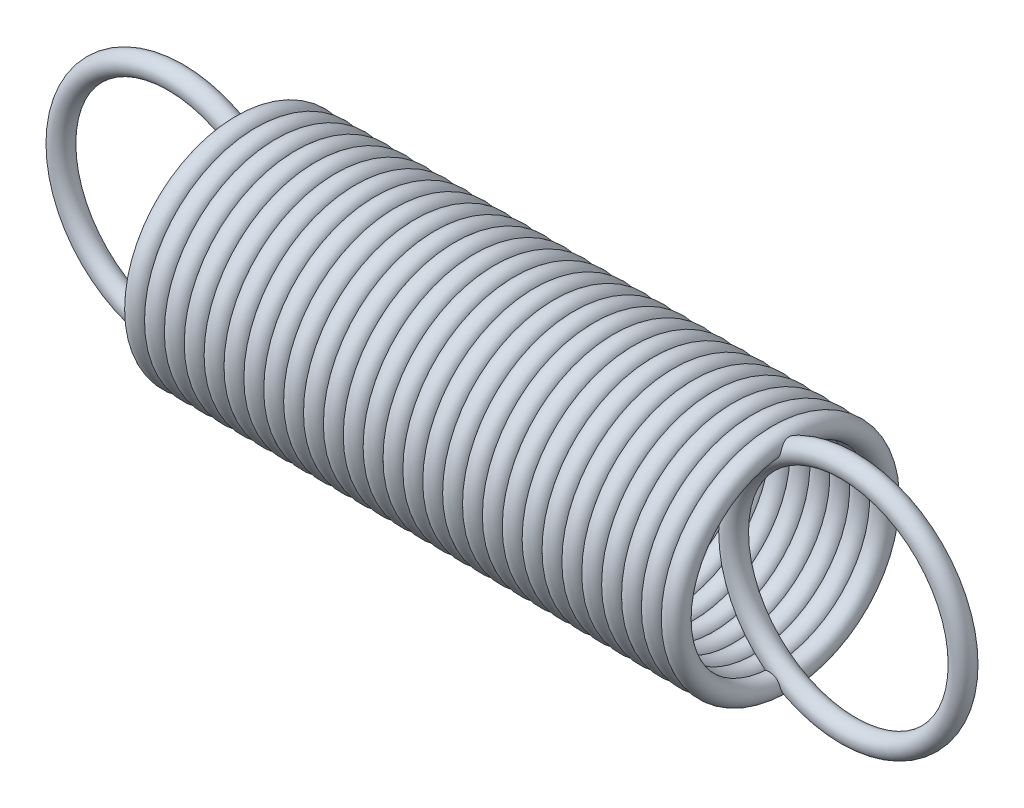
from build123d import *

# Parameters (mm, degrees)
SKETCH4_R       = 0.2921
LPATTERN3_COUNT = 28
LPATTERN3_PITCH = 0.55
SKETCH3_R       = 0.2921
SKETCH7_R       = 0.2921


with BuildPart() as part:
    # Sketch4 → Revolve2 (revolve)
    with BuildSketch(Plane(origin=(0, 0, 0), x_dir=(1, 0, 0), z_dir=(0, 1, 0))):
        with Locations((0, 2.8829)):
            Circle(SKETCH4_R)
    revolve(axis=Axis((-3.147709024, 0, 0), (1, 0, 0)))


with BuildPart() as lpattern3_1:
    # LPattern3: pattern copy
    add(part.part.moved(Location(Vector(1, 0, 0) * (1 * LPATTERN3_PITCH))))


with BuildPart() as lpattern3_2:
    # LPattern3: pattern copy
    add(part.part.moved(Location(Vector(1, 0, 0) * (2 * LPATTERN3_PITCH))))


with BuildPart() as lpattern3_3:
    # LPattern3: pattern copy
    add(part.part.moved(Location(Vector(1, 0, 0) * (3 * LPATTERN3_PITCH))))


with BuildPart() as lpattern3_4:
    # LPattern3: pattern copy
    add(part.part.moved(Location(Vector(1, 0, 0) * (4 * LPATTERN3_PITCH))))


with BuildPart() as lpattern3_5:
    # LPattern3: pattern copy
    add(part.part.moved(Location(Vector(1, 0, 0) * (5 * LPATTERN3_PITCH))))


with BuildPart() as lpattern3_6:
    # LPattern3: pattern copy
    add(part.part.moved(Location(Vector(1, 0, 0) * (6 * LPATTERN3_PITCH))))


with BuildPart() as lpattern3_7:
    # LPattern3: pattern copy
    add(part.part.moved(Location(Vector(1, 0, 0) * (7 * LPATTERN3_PITCH))))


with BuildPart() as lpattern3_8:
    # LPattern3: pattern copy
    add(part.part.moved(Location(Vector(1, 0, 0) * (8 * LPATTERN3_PITCH))))


with BuildPart() as lpattern3_9:
    # LPattern3: pattern copy
    add(part.part.moved(Location(Vector(1, 0, 0) * (9 * LPATTERN3_PITCH))))


with BuildPart() as lpattern3_10:
    # LPattern3: pattern copy
    add(part.part.moved(Location(Vector(1, 0, 0) * (10 * LPATTERN3_PITCH))))


with BuildPart() as lpattern3_11:
    # LPattern3: pattern copy
    add(part.part.moved(Location(Vector(1, 0, 0) * (11 * LPATTERN3_PITCH))))


with BuildPart() as lpattern3_12:
    # LPattern3: pattern copy
    add(part.part.moved(Location(Vector(1, 0, 0) * (12 * LPATTERN3_PITCH))))


with BuildPart() as lpattern3_13:
    # LPattern3: pattern copy
    add(part.part.moved(Location(Vector(1, 0, 0) * (13 * LPATTERN3_PITCH))))


with BuildPart() as lpattern3_14:
    # LPattern3: pattern copy
    add(part.part.moved(Location(Vector(1, 0, 0) * (14 * LPATTERN3_PITCH))))


with BuildPart() as lpattern3_15:
    # LPattern3: pattern copy
    add(part.part.moved(Location(Vector(1, 0, 0) * (15 * LPATTERN3_PITCH))))


with BuildPart() as lpattern3_16:
    # LPattern3: pattern copy
    add(part.part.moved(Location(Vector(1, 0, 0) * (16 * LPATTERN3_PITCH))))


with BuildPart() as lpattern3_17:
    # LPattern3: pattern copy
    add(part.part.moved(Location(Vector(1, 0, 0) * (17 * LPATTERN3_PITCH))))


with BuildPart() as lpattern3_18:
    # LPattern3: pattern copy
    add(part.part.moved(Location(Vector(1, 0, 0) * (18 * LPATTERN3_PITCH))))


with BuildPart() as lpattern3_19:
    # LPattern3: pattern copy
    add(part.part.moved(Location(Vector(1, 0, 0) * (19 * LPATTERN3_PITCH))))


with BuildPart() as lpattern3_20:
    # LPattern3: pattern copy
    add(part.part.moved(Location(Vector(1, 0, 0) * (20 * LPATTERN3_PITCH))))


with BuildPart() as lpattern3_21:
    # LPattern3: pattern copy
    add(part.part.moved(Location(Vector(1, 0, 0) * (21 * LPATTERN3_PITCH))))


with BuildPart() as lpattern3_22:
    # LPattern3: pattern copy
    add(part.part.moved(Location(Vector(1, 0, 0) * (22 * LPATTERN3_PITCH))))


with BuildPart() as lpattern3_23:
    # LPattern3: pattern copy
    add(part.part.moved(Location(Vector(1, 0, 0) * (23 * LPATTERN3_PITCH))))


with BuildPart() as lpattern3_24:
    # LPattern3: pattern copy
    add(part.part.moved(Location(Vector(1, 0, 0) * (24 * LPATTERN3_PITCH))))


with BuildPart() as lpattern3_25:
    # LPattern3: pattern copy
    add(part.part.moved(Location(Vector(1, 0, 0) * (25 * LPATTERN3_PITCH))))


with BuildPart() as lpattern3_26:
    # LPattern3: pattern copy
    add(part.part.moved(Location(Vector(1, 0, 0) * (26 * LPATTERN3_PITCH))))


with BuildPart() as lpattern3_27:
    # LPattern3: pattern copy
    add(part.part.moved(Location(Vector(1, 0, 0) * (27 * LPATTERN3_PITCH))))


with BuildPart() as body_29:
    # Sketch3 → Revolve1 (revolve)
    with BuildSketch(Plane(origin=(0, 0, 0), x_dir=(1, 0, 0), z_dir=(0, 1, 0))):
        with Locations((-5.05881325, 0)):
            Circle(SKETCH3_R)
    revolve(axis=Axis((-1.88381325, 0, 1.393812818), (0, 0, -1)))


with BuildPart() as body_30:
    # Sketch7 → Revolve3 (revolve)
    with BuildSketch(Plane(origin=(0, 0, 0), x_dir=(1, 0, 0), z_dir=(0, 1, 0))):
        with Locations((19.906826885, 0)):
            Circle(SKETCH7_R)
    revolve(axis=Axis((16.731826885, 0, 0.282594352), (0, 0, -1)))


solid = Compound([part.part, lpattern3_1.part, lpattern3_2.part, lpattern3_3.part, lpattern3_4.part, lpattern3_5.part, lpattern3_6.part, lpattern3_7.part, lpattern3_8.part, lpattern3_9.part, lpattern3_10.part, lpattern3_11.part, lpattern3_12.part, lpattern3_13.part, lpattern3_14.part, lpattern3_15.part, lpattern3_16.part, lpattern3_17.part, lpattern3_18.part, lpattern3_19.part, lpattern3_20.part, lpattern3_21.part, lpattern3_22.part, lpattern3_23.part, lpattern3_24.part, lpattern3_25.part, lpattern3_26.part, lpattern3_27.part, body_29.part, body_30.part])
